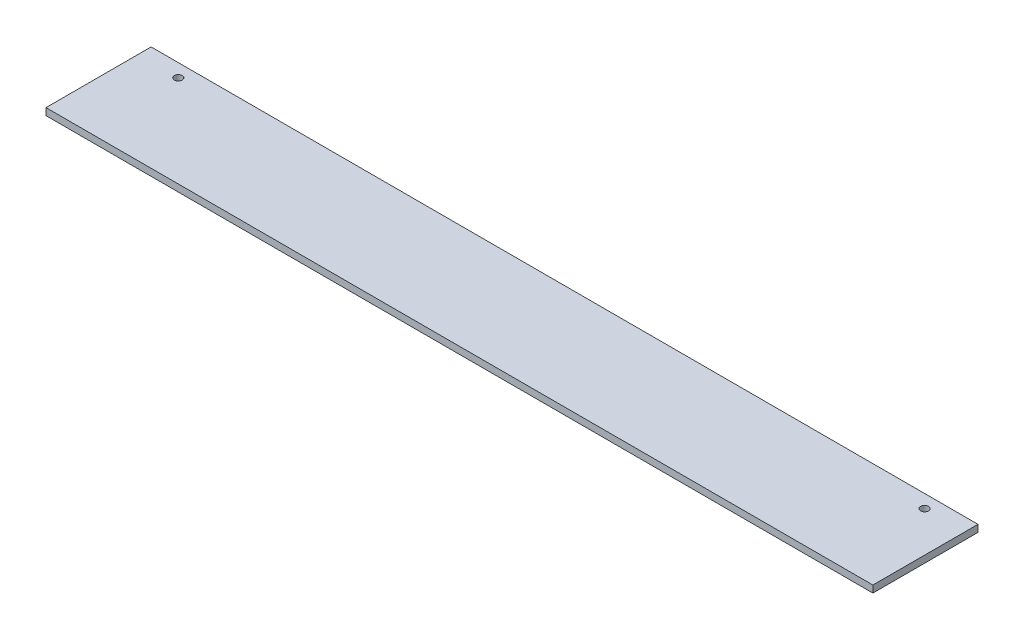
from build123d import *

# Parameters (mm, degrees)
SKETCH_1_W          = 60
SKETCH_1_H          = 4
EXTRUDE_1_DEPTH     = 472
SKETCH_2_R          = 2.25
CUT_EXTRUDE_1_DEPTH = 5


with BuildPart() as part:
    # Эскиз1 → Бобышка-Вытянуть1 (new body)
    with BuildSketch(Plane(origin=(0, 0, 0), x_dir=(0, 0, -1), z_dir=(1, 0, 0))):
        Rectangle(SKETCH_1_W, SKETCH_1_H)
    extrude(amount=EXTRUDE_1_DEPTH)

    # Эскиз2 → Вырез-Вытянуть1 (cut, through all)
    with BuildSketch(Plane(origin=(0, 2, 0), x_dir=(1, 0, 0), z_dir=(0, 1, 0))):
        with Locations((23, 22.5)):
            Circle(SKETCH_2_R)
        with Locations((449, 22.5)):
            Circle(SKETCH_2_R)
    extrude(amount=-CUT_EXTRUDE_1_DEPTH, mode=Mode.SUBTRACT)


solid = part.part
